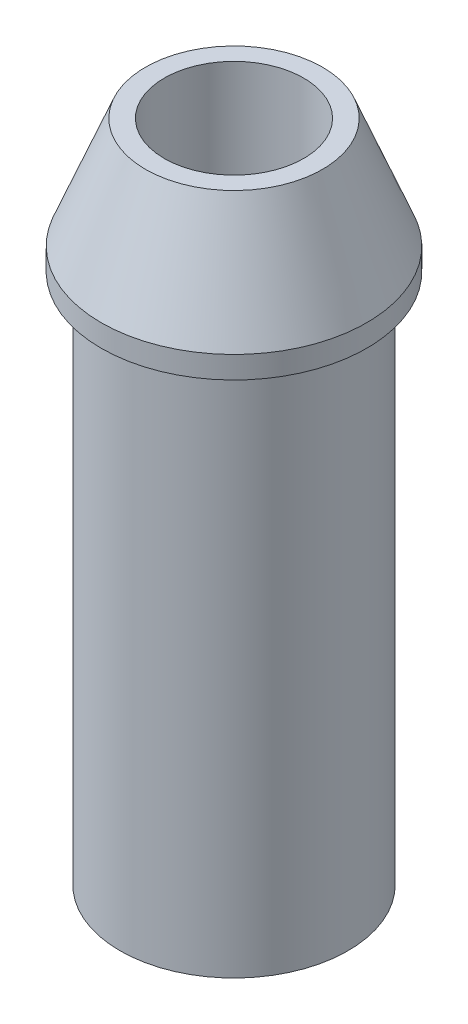
from build123d import *

# Parameters (mm, degrees)
SKETCH1_R           = 2.575
SKETCH1_R_2         = 1.575
BOSS_EXTRUDE1_DEPTH = 15
SKETCH2_R           = 3
SKETCH2_R_2         = 1.575
BOSS_EXTRUDE2_DEPTH = 3
CHAMFER1_SIZE       = 2.5
CHAMFER1_SIZE2      = 1


with BuildPart() as part:
    # Sketch1 → Boss-Extrude1 (new body)
    with BuildSketch(Plane(origin=(0, 0, 0), x_dir=(1, 0, 0), z_dir=(0, 1, 0))):
        Circle(SKETCH1_R)
        Circle(SKETCH1_R_2, mode=Mode.SUBTRACT)
    extrude(amount=BOSS_EXTRUDE1_DEPTH)

    # Sketch2 → Boss-Extrude2 (add)
    with BuildSketch(Plane(origin=(0, 15, 0), x_dir=(1, 0, 0), z_dir=(0, 1, 0))):
        Circle(SKETCH2_R)
        Circle(SKETCH2_R_2, mode=Mode.SUBTRACT)
    extrude(amount=-BOSS_EXTRUDE2_DEPTH)

    # Chamfer1
    chamfer1_edges = [part.edges().sort_by_distance(p)[0] for p in [
        (-3, 15, 0),
    ]]
    chamfer1_side = [part.faces().sort_by_distance(p)[0] for p in [
        (-3, 13.5, 0),
    ]]
    chamfer(chamfer1_edges, length=CHAMFER1_SIZE, length2=CHAMFER1_SIZE2, reference=chamfer1_side[0])


solid = part.part
